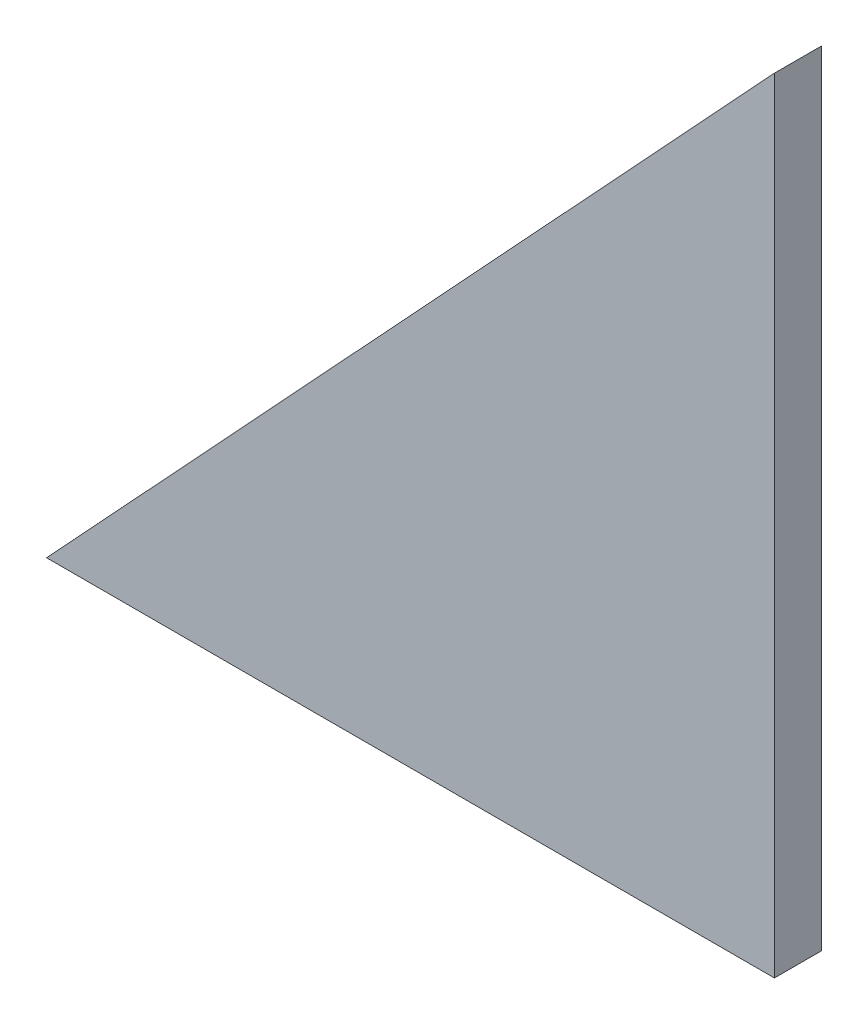
from build123d import *

# Parameters (mm, degrees)
DODANIE_WYCI_GNI_CIE1_DEPTH = 2
SZKIC2_R                    = 12.5
WYTNIJ_WYCI_GNI_CIE1_DEPTH  = 25


with BuildPart() as part:
    # Szkic1 → Dodanie-wyciągnięcie1 (new body)
    with BuildSketch(Plane(origin=(0, 0, -1.5), x_dir=(-1, 0, 0), z_dir=(0, 0, -1))):
        Polygon((23.22, 0), (0, 25), (0, 0), align=None)
    extrude(amount=-DODANIE_WYCI_GNI_CIE1_DEPTH)

    # Szkic2 → Wytnij-wyciągnięcie1 (cut)
    with BuildSketch(Plane(origin=(0, 0, 0), x_dir=(-1, 0, 0), z_dir=(0, -1, 0))):
        with Locations((-6.78, 11.501504654)):
            Circle(SZKIC2_R)
    extrude(amount=-WYTNIJ_WYCI_GNI_CIE1_DEPTH, mode=Mode.SUBTRACT)


solid = part.part
